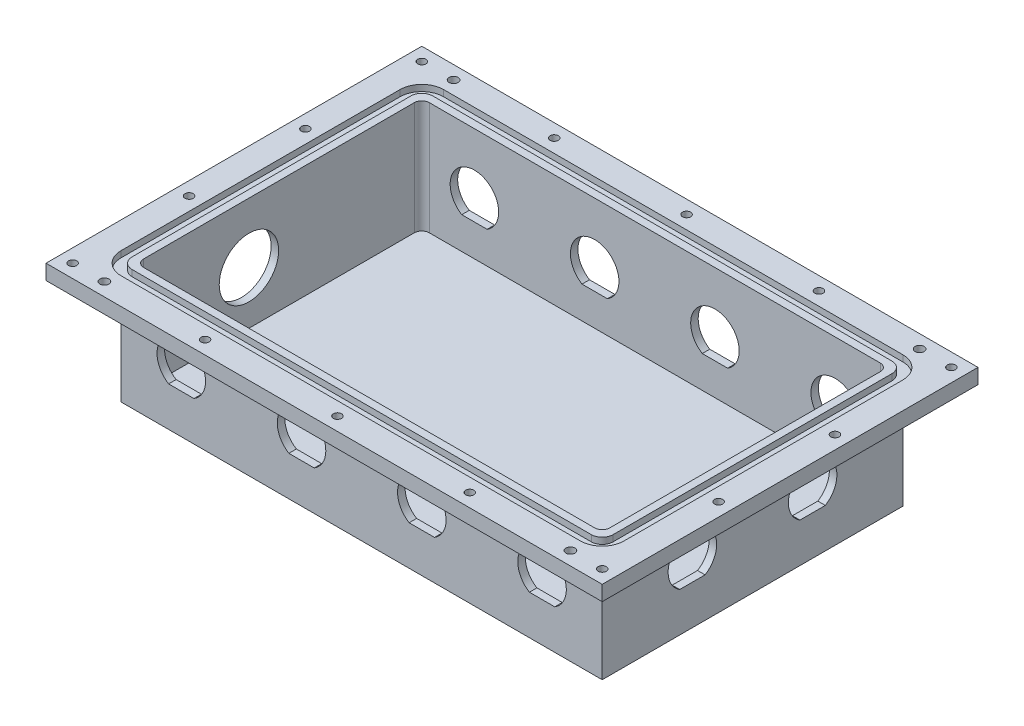
from build123d import *

# Parameters (mm, degrees)
SKETCH1_W             = 203.2
SKETCH1_H             = 127
BOSS_EXTRUDE1_DEPTH   = 50.8
SKETCH2_W             = 196.85
SKETCH2_H             = 120.65
CUT_EXTRUDE1_DEPTH    = 47.625
SKETCH4_W             = 234.95
SKETCH4_H             = 158.75
SKETCH4_W_2           = 203.2
SKETCH4_H_2           = 127
BOSS_EXTRUDE2_DEPTH   = 6.35
SKETCH7_W             = 212.4456
SKETCH7_H             = 136.2456
SKETCH7_W_2           = 203.2
SKETCH7_H_2           = 127
CUT_EXTRUDE2_DEPTH    = 2.6416
F_8_32_TAPPED_HOLE1_D = 3.4544
FILLET3_R             = 4.6228
FILLET4_R             = 9.2456
CUT_EXTRUDE5_DEPTH    = 143.875
CUT_EXTRUDE6_REACH    = 221.075
CUT_EXTRUDE7_REACH    = 221.075
SKETCH13_R            = 12.55395
FILLET5_R             = 3.175
F_6_CLEARANCE_HOLE1_D = 3.7973


with BuildPart() as part:
    # Sketch1 → Boss-Extrude1 (new body)
    with BuildSketch(Plane(origin=(0, 0, 0), x_dir=(1, 0, 0), z_dir=(0, 1, 0))):
        Rectangle(SKETCH1_W, SKETCH1_H)
    extrude(amount=BOSS_EXTRUDE1_DEPTH)

    # Sketch2 → Cut-Extrude1 (cut)
    with BuildSketch(Plane(origin=(0, 50.8, 0), x_dir=(1, 0, 0), z_dir=(0, 1, 0))):
        Rectangle(SKETCH2_W, SKETCH2_H)
    extrude(amount=-CUT_EXTRUDE1_DEPTH, mode=Mode.SUBTRACT)

    # Sketch4 → Boss-Extrude2 (add)
    with BuildSketch(Plane(origin=(0, 50.8, 0), x_dir=(1, 0, 0), z_dir=(0, 1, 0))):
        Rectangle(SKETCH4_W, SKETCH4_H)
        Rectangle(SKETCH4_W_2, SKETCH4_H_2, mode=Mode.SUBTRACT)
    extrude(amount=-BOSS_EXTRUDE2_DEPTH)

    # Sketch7 → Cut-Extrude2 (cut)
    with BuildSketch(Plane(origin=(0, 50.8, 0), x_dir=(1, 0, 0), z_dir=(0, 1, 0))):
        Rectangle(SKETCH7_W, SKETCH7_H)
        Rectangle(SKETCH7_W_2, SKETCH7_H_2, mode=Mode.SUBTRACT)
    extrude(amount=-CUT_EXTRUDE2_DEPTH, mode=Mode.SUBTRACT)

    # #8-32 Tapped Hole1 (through all)
    with Locations(Plane(origin=(0, 50.8, 0), x_dir=(1, 0, 0), z_dir=(0, 1, 0))):
        with Locations((55.92445, 73.7489), (111.8489, 73.7489), (111.8489, 24.582966667), (0, 73.7489), (111.8489, -24.582966667), (111.8489, -73.7489), (55.92445, -73.7489), (0, -73.7489), (-55.92445, -73.7489), (-111.8489, -73.7489), (-111.8489, -24.582966667), (-111.8489, 24.582966667), (-111.8489, 73.7489), (-55.92445, 73.7489)):
            Hole(F_8_32_TAPPED_HOLE1_D / 2)

    # Fillet3
    fillet3_edges = [part.edges().sort_by_distance(p)[0] for p in [
        (-101.6, 49.4792, -63.5),
        (101.6, 49.4792, -63.5),
        (101.6, 49.4792, 63.5),
        (-101.6, 49.4792, 63.5),
    ]]
    fillet(fillet3_edges, radius=FILLET3_R)

    # Fillet4
    fillet4_edges = [part.edges().sort_by_distance(p)[0] for p in [
        (-106.2228, 49.4792, -68.1228),
        (106.2228, 49.4792, -68.1228),
        (106.2228, 49.4792, 68.1228),
        (-106.2228, 49.4792, 68.1228),
    ]]
    fillet(fillet4_edges, radius=FILLET4_R)

    # Sketch10 → Cut-Extrude5 (cut, through all)
    with BuildSketch(Plane.XY.offset(63.5)):
        with BuildLine():
            ThreePointArc((-70.843294161, 16.6624), (-76.2, 35.6489), (-81.556705839, 16.6624))
            Line((-81.556705839, 16.6624), (-70.843294161, 16.6624))
        make_face()
        with BuildLine():
            ThreePointArc((81.556705839, 16.6624), (76.2, 35.6489), (70.843294161, 16.6624))
            Line((70.843294161, 16.6624), (81.556705839, 16.6624))
        make_face()
        with BuildLine():
            ThreePointArc((30.756705839, 16.6624), (25.4, 35.6489), (20.043294161, 16.6624))
            Line((20.043294161, 16.6624), (30.756705839, 16.6624))
        make_face()
        with BuildLine():
            ThreePointArc((-20.043294161, 16.6624), (-25.4, 35.6489), (-30.756705839, 16.6624))
            Line((-30.756705839, 16.6624), (-20.043294161, 16.6624))
        make_face()
    extrude(amount=-CUT_EXTRUDE5_DEPTH, mode=Mode.SUBTRACT)

    # Sketch12 → Cut-Extrude6 (cut, up to next)
    with BuildSketch(Plane(origin=(101.6, 0, 0), x_dir=(0, 0, -1), z_dir=(1, 0, 0)), mode=Mode.PRIVATE) as cut_extrude6_sk1:
        with BuildLine():
            ThreePointArc((-20.043294161, 16.6624), (-25.4, 35.6489), (-30.756705839, 16.6624))
            Line((-30.756705839, 16.6624), (-20.043294161, 16.6624))
        make_face()
    cut_extrude6_tool1 = extrude(cut_extrude6_sk1.sketch, amount=-CUT_EXTRUDE6_REACH, mode=Mode.PRIVATE) & part.part
    add(cut_extrude6_tool1.solids().sort_by_distance((101.6, 25.721198, 25.4))[0], mode=Mode.SUBTRACT)
    # Sketch12 → Cut-Extrude6 (cut, up to next)
    with BuildSketch(Plane(origin=(101.6, 0, 0), x_dir=(0, 0, -1), z_dir=(1, 0, 0)), mode=Mode.PRIVATE) as cut_extrude6_sk2:
        with BuildLine():
            ThreePointArc((30.756705839, 16.6624), (25.4, 35.6489), (20.043294161, 16.6624))
            Line((20.043294161, 16.6624), (30.756705839, 16.6624))
        make_face()
    cut_extrude6_tool2 = extrude(cut_extrude6_sk2.sketch, amount=-CUT_EXTRUDE6_REACH, mode=Mode.PRIVATE) & part.part
    add(cut_extrude6_tool2.solids().sort_by_distance((101.6, 25.721198, -25.4))[0], mode=Mode.SUBTRACT)

    # Sketch13 → Cut-Extrude7 (cut, up to next)
    with BuildSketch(Plane.ZY.offset(101.6), mode=Mode.PRIVATE) as cut_extrude7_sk1:
        with Locations((12.7, 25.4)):
            Circle(SKETCH13_R)
    cut_extrude7_tool1 = extrude(cut_extrude7_sk1.sketch, amount=-CUT_EXTRUDE7_REACH, mode=Mode.PRIVATE) & part.part
    add(cut_extrude7_tool1.solids().sort_by_distance((-101.6, 25.4, 12.7))[0], mode=Mode.SUBTRACT)

    # Fillet5
    fillet5_edges = [part.edges().sort_by_distance(p)[0] for p in [
        (-98.425, 26.9875, -60.325),
        (98.425, 26.9875, -60.325),
        (98.425, 26.9875, 60.325),
        (-98.425, 26.9875, 60.325),
    ]]
    fillet(fillet5_edges, radius=FILLET5_R)

    # #6 Clearance Hole1 (through all)
    with Locations(Plane(origin=(0, 44.45, 0), x_dir=(-1, 0, 0), z_dir=(0, -1, 0))):
        with Locations((-98.425, 73.7489), (-98.425, -73.7489), (98.425, -73.7489), (98.425, 73.7489)):
            Hole(F_6_CLEARANCE_HOLE1_D / 2)


solid = part.part
